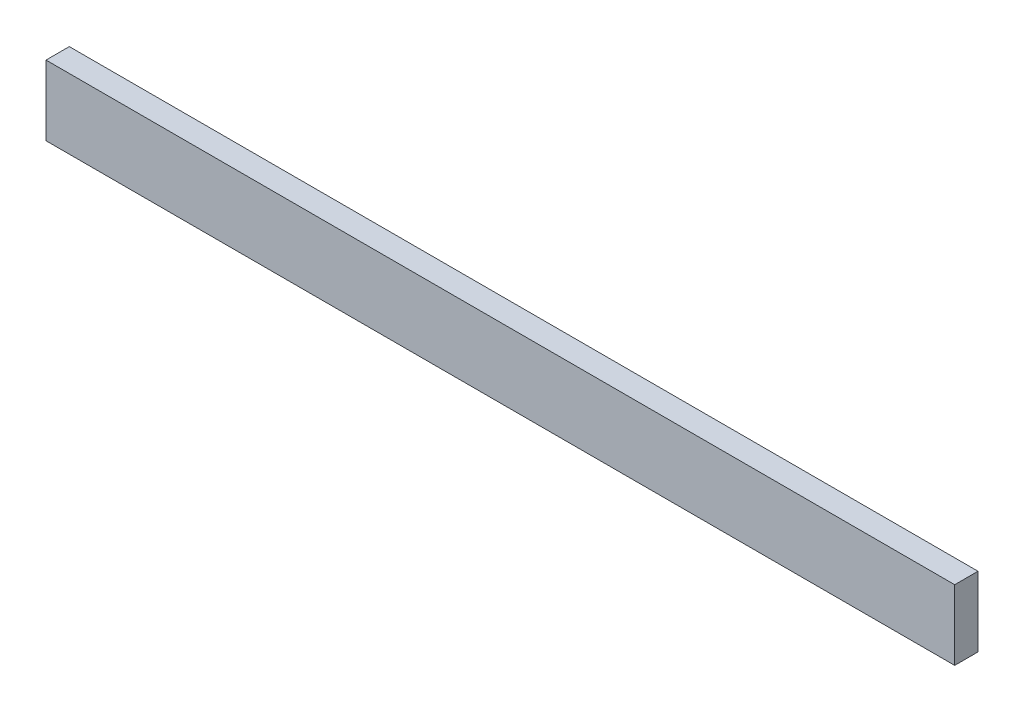
from build123d import *

# Parameters (mm, degrees)
SKETCH2_W           = 247.65
SKETCH2_H           = 19.05
BOSS_EXTRUDE1_DEPTH = 6.35


with BuildPart() as part:
    # Sketch2 → Boss-Extrude1 (new body)
    with BuildSketch(Plane.XY):
        with Locations((123.825, 9.525)):
            Rectangle(SKETCH2_W, SKETCH2_H)
    extrude(amount=BOSS_EXTRUDE1_DEPTH)


solid = part.part
